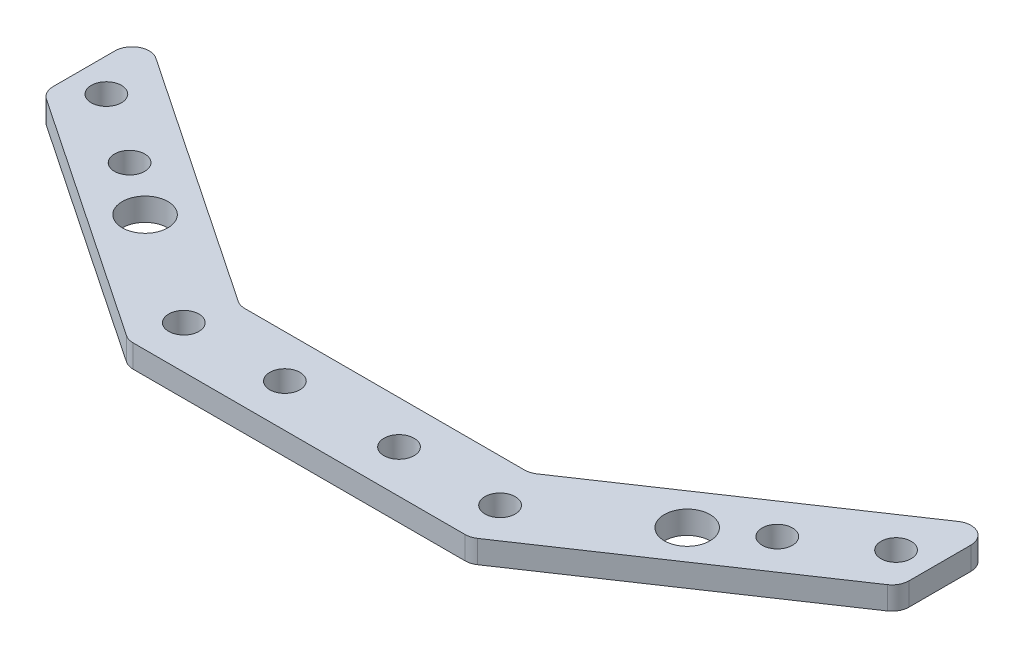
from build123d import *

# Parameters (mm, degrees)
SKETCH_1_R               = 275
SKETCH_1_R_2             = 255
EXTRUDE_1_DEPTH          = 10
EXTRUDE_2_DEPTH          = 10
SKETCH_8_R               = 2.65
SKETCH_8_R_2             = 1.65
SKETCH_8_R_3             = 2.15
CUT_EXTRUDE_1_DEPTH      = 21
SKETCH_9_OUTSIDE_W       = 707.614
SKETCH_9_OUTSIDE_H       = 707.614
CUT_EXTRUDE_2_DEPTH      = 21
SKETCH_10_W              = 150
SKETCH_10_H              = 32
CUT_EXTRUDE_3_DEPTH      = 91
SKETCH_11_R              = 275
SKETCH_11_R_2            = 255
CUT_EXTRUDE_4_DEPTH      = 11
CUT_EXTRUDE_4_DEPTH_BACK = 11
FILLET_1_R               = 3
SKETCH_13_R              = 4
CUT_EXTRUDE_6_DEPTH      = 5


with BuildPart() as part:
    # 草图1 → 凸台-拉伸1 (new body)
    with BuildSketch(Plane(origin=(0, 0, 0), x_dir=(1, 0, 0), z_dir=(0, 1, 0))):
        Circle(SKETCH_1_R)
        Circle(SKETCH_1_R_2, mode=Mode.SUBTRACT)
    extrude(amount=EXTRUDE_1_DEPTH)

    # 草图11 → 切除-拉伸4 (cut, two sides)
    with BuildSketch(Plane(origin=(0, 10, 0), x_dir=(1, 0, 0), z_dir=(0, 1, 0))) as cut_extrude_4_sk:
        Circle(SKETCH_11_R)
        Circle(SKETCH_11_R_2, mode=Mode.SUBTRACT)
    extrude(amount=CUT_EXTRUDE_4_DEPTH, mode=Mode.SUBTRACT)
    extrude(cut_extrude_4_sk.sketch, amount=-CUT_EXTRUDE_4_DEPTH_BACK, mode=Mode.SUBTRACT)


with BuildPart() as body_2:
    # 草图2 → 凸台-拉伸2 (new body)
    with BuildSketch(Plane(origin=(0, 10, 0), x_dir=(1, 0, 0), z_dir=(0, 1, 0))):
        with BuildLine():
            Line((-110.525139894, 257.262887824), (-25.423255477, 200))
            Line((-25.423255477, 200), (0, 200))
            Line((0, 200), (25.423255477, 200))
            Line((25.423255477, 200), (110.525139894, 257.262887824))
            ThreePointArc((110.525139894, 257.262887824), (197.989898732, 197.989898732), (257.262887824, 110.525139894))
            Line((257.262887824, 110.525139894), (200, 25.423255477))
            Line((200, 25.423255477), (200, 0))
            Line((200, 0), (200, -25.423255477))
            Line((200, -25.423255477), (257.262887824, -110.525139894))
            ThreePointArc((257.262887824, -110.525139894), (197.989898732, -197.989898732), (110.525139894, -257.262887824))
            Line((110.525139894, -257.262887824), (25.423255477, -200))
            Line((25.423255477, -200), (0, -200))
            Line((0, -200), (-25.423255477, -200))
            Line((-25.423255477, -200), (-110.525139894, -257.262887824))
            ThreePointArc((-110.525139894, -257.262887824), (-197.989898732, -197.989898732), (-257.262887824, -110.525139894))
            Line((-257.262887824, -110.525139894), (-200, -25.423255477))
            Line((-200, -25.423255477), (-200, 25.423255477))
            Line((-200, 25.423255477), (-257.262887824, 110.525139894))
            ThreePointArc((-257.262887824, 110.525139894), (-197.989898732, 197.989898732), (-110.525139894, 257.262887824))
        make_face()
        with BuildLine():
            Line((0, 185), (30, 185))
            Line((30, 185), (111.993839361, 240.171563565))
            ThreePointArc((111.993839361, 240.171563565), (187.383297014, 187.383297014), (240.171563565, 111.993839361))
            Line((240.171563565, 111.993839361), (185, 30))
            Line((185, 30), (185, 0))
            Line((185, 0), (185, -30))
            Line((185, -30), (240.171563565, -111.993839361))
            ThreePointArc((240.171563565, -111.993839361), (187.383297014, -187.383297014), (111.993839361, -240.171563565))
            Line((111.993839361, -240.171563565), (30, -185))
            Line((30, -185), (0, -185))
            Line((0, -185), (-30, -185))
            Line((-30, -185), (-111.993839361, -240.171563565))
            ThreePointArc((-111.993839361, -240.171563565), (-187.383297014, -187.383297014), (-240.171563565, -111.993839361))
            Line((-240.171563565, -111.993839361), (-185, -30))
            Line((-185, -30), (-185, 30))
            Line((-185, 30), (-240.171563565, 111.993839361))
            ThreePointArc((-240.171563565, 111.993839361), (-187.383297014, 187.383297014), (-111.993839361, 240.171563565))
            Line((-111.993839361, 240.171563565), (-30, 185))
            Line((-30, 185), (0, 185))
        make_face(mode=Mode.SUBTRACT)
    extrude(amount=EXTRUDE_2_DEPTH)

    # 草图8 → 切除-拉伸1 (cut, through all)
    with BuildSketch(Plane(origin=(0, 20, 0), x_dir=(1, 0, 0), z_dir=(0, 1, 0))):
        with Locations((-10, 192.5)):
            Circle(SKETCH_8_R)
        with Locations((10, 192.5)):
            Circle(SKETCH_8_R)
        with Locations((-10, -192.5)):
            Circle(SKETCH_8_R)
        with Locations((10, -192.5)):
            Circle(SKETCH_8_R)
        with Locations((192.5, 10)):
            Circle(SKETCH_8_R)
        with Locations((192.5, -10)):
            Circle(SKETCH_8_R)
        with Locations((-192.5, 10)):
            Circle(SKETCH_8_R)
        with Locations((-192.5, -10)):
            Circle(SKETCH_8_R)
        with Locations((-110.525139894, 248.223100485)):
            Circle(SKETCH_8_R_2)
        with Locations((-27.711627738, 192.5)):
            Circle(SKETCH_8_R)
        with Locations((-56.749921469, 212.03912734)):
            Circle(SKETCH_8_R)
        with Locations((-69.194904497, 220.413039057)):
            Circle(SKETCH_8_R)
        with Locations((-81.639887524, 228.786950774)):
            Circle(SKETCH_8_R)
        with Locations((-146.077022117, 230.028561882)):
            Circle(SKETCH_8_R_3)
        with Locations((-164.415519771, 217.299729706)):
            Circle(SKETCH_8_R_3)
        with Locations((-183.638937552, 201.316607082)):
            Circle(SKETCH_8_R_3)
        with Locations((-201.316607082, 183.638937552)):
            Circle(SKETCH_8_R_3)
        with Locations((-217.299729706, 164.415519771)):
            Circle(SKETCH_8_R_3)
        with Locations((-230.028561882, 146.077022117)):
            Circle(SKETCH_8_R_3)
        with Locations((-128.811575358, 240.123330241)):
            Circle(SKETCH_8_R)
        with Locations((-240.123330241, 128.811575358)):
            Circle(SKETCH_8_R)
        with Locations((-228.786950774, 81.639887524)):
            Circle(SKETCH_8_R)
        with Locations((-220.413039057, 69.194904497)):
            Circle(SKETCH_8_R)
        with Locations((-212.03912734, 56.749921469)):
            Circle(SKETCH_8_R)
        with Locations((-203.665215623, 44.304938442)):
            Circle(SKETCH_8_R)
        with Locations((-192.5, 27.711627738)):
            Circle(SKETCH_8_R)
        with Locations((-248.223100485, 110.525139894)):
            Circle(SKETCH_8_R_2)
        with Locations((192.5, 27.711627738)):
            Circle(SKETCH_8_R)
        with Locations((248.223100485, 110.525139894)):
            Circle(SKETCH_8_R_2)
        with Locations((203.665215623, 44.304938442)):
            Circle(SKETCH_8_R)
        with Locations((212.03912734, 56.749921469)):
            Circle(SKETCH_8_R)
        with Locations((220.413039057, 69.194904497)):
            Circle(SKETCH_8_R)
        with Locations((228.786950774, 81.639887524)):
            Circle(SKETCH_8_R)
        with Locations((240.123330241, 128.811575358)):
            Circle(SKETCH_8_R)
        with Locations((230.028561882, 146.077022117)):
            Circle(SKETCH_8_R_3)
        with Locations((128.811575358, 240.123330241)):
            Circle(SKETCH_8_R)
        with Locations((201.316607082, 183.638937552)):
            Circle(SKETCH_8_R_3)
        with Locations((183.638937552, 201.316607082)):
            Circle(SKETCH_8_R_3)
        with Locations((164.415519771, 217.299729706)):
            Circle(SKETCH_8_R_3)
        with Locations((146.077022117, 230.028561882)):
            Circle(SKETCH_8_R_3)
        with Locations((81.639887524, 228.786950774)):
            Circle(SKETCH_8_R)
        with Locations((69.194904497, 220.413039057)):
            Circle(SKETCH_8_R)
        with Locations((56.749921469, 212.03912734)):
            Circle(SKETCH_8_R)
        with Locations((110.525139894, 248.223100485)):
            Circle(SKETCH_8_R_2)
        with Locations((27.711627738, 192.5)):
            Circle(SKETCH_8_R)
        with Locations((217.299729706, 164.415519771)):
            Circle(SKETCH_8_R_3)
    extrude(amount=-CUT_EXTRUDE_1_DEPTH, mode=Mode.SUBTRACT)

    # 草图9 outside → 切除-拉伸2 (cut, through all)
    with BuildSketch(Plane(origin=(0, 20, 0), x_dir=(1, 0, 0), z_dir=(0, 1, 0))):
        Rectangle(SKETCH_9_OUTSIDE_W, SKETCH_9_OUTSIDE_H)
        Polygon((-75, 233.358927123), (-75, 215.279352446), (-30, 185), (30, 185), (75, 215.279352446), (75, 233.358927123), (25.423255477, 200), (-25.423255477, 200), align=None, mode=Mode.SUBTRACT)
    extrude(amount=-CUT_EXTRUDE_2_DEPTH, mode=Mode.SUBTRACT)

    # 草图10 → 切除-拉伸3 (cut, through all)
    with BuildSketch(Plane.XY.offset(-185)):
        Rectangle(SKETCH_10_W, SKETCH_10_H)
    extrude(amount=-CUT_EXTRUDE_3_DEPTH, mode=Mode.SUBTRACT)

    # 圆角1
    fillet_1_edges = [body_2.edges().sort_by_distance(p)[0] for p in [
        (-25.423255477, 18, -200),
        (25.423255477, 18, -200),
        (-75, 18, -215.279352446),
        (75, 18, -233.358927123),
        (75, 18, -215.279352446),
        (-75, 18, -233.358927123),
        (30, 18, -185),
        (-30, 18, -185),
    ]]
    fillet(fillet_1_edges, radius=FILLET_1_R)

    # 草图13 → 切除-拉伸6 (cut, through all)
    with BuildSketch(Plane.XZ.offset(-16)):
        with Locations((-47.5, -205.5)):
            Circle(SKETCH_13_R)
        with Locations((47.5, -205.5)):
            Circle(SKETCH_13_R)
    extrude(amount=-CUT_EXTRUDE_6_DEPTH, mode=Mode.SUBTRACT)


solid = body_2.part
